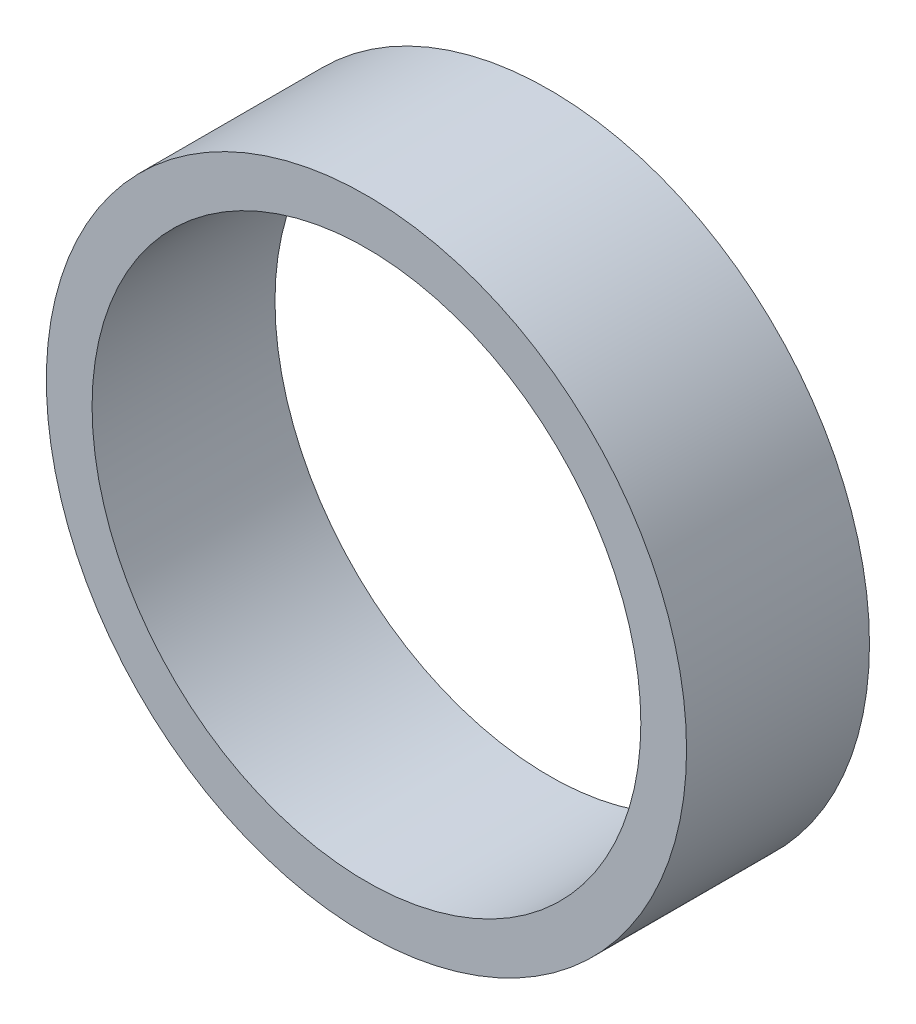
from build123d import *

# Parameters (mm, degrees)
SKETCH1_R           = 3.5
SKETCH1_R_2         = 3
BOSS_EXTRUDE1_DEPTH = 2


with BuildPart() as part:
    # Sketch1 → Boss-Extrude1 (new body)
    with BuildSketch(Plane.XY):
        Circle(SKETCH1_R)
        Circle(SKETCH1_R_2, mode=Mode.SUBTRACT)
    extrude(amount=BOSS_EXTRUDE1_DEPTH)


solid = part.part
